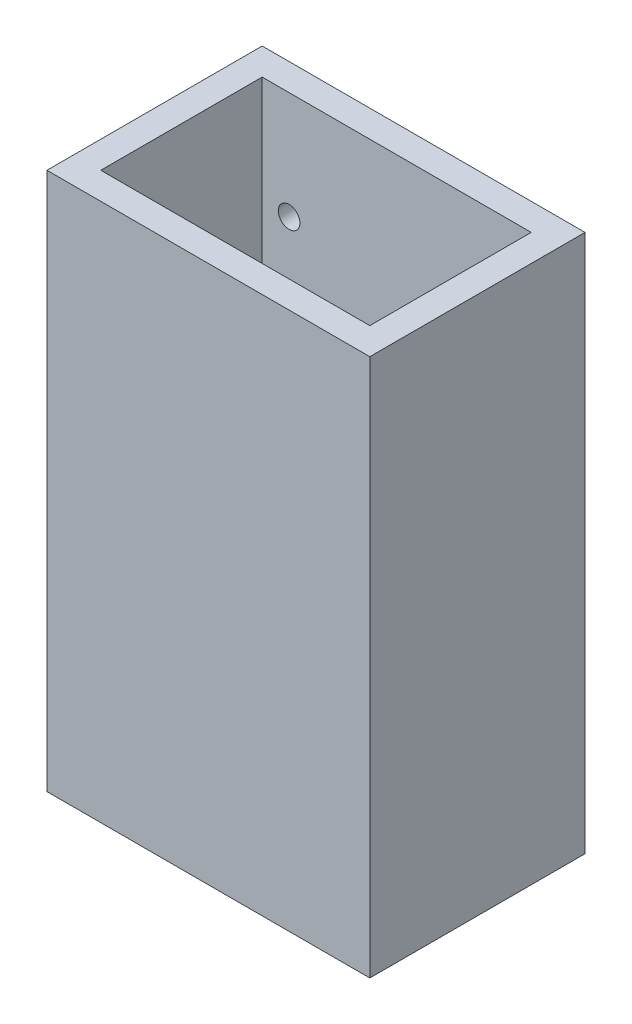
from build123d import *

# Parameters (mm, degrees)
SKETCH1_W                   = 76.2
SKETCH1_H                   = 50.8
SKETCH1_W_2                 = 63.5
SKETCH1_H_2                 = 38.1
BOSS_EXTRUDE1_DEPTH         = 127
F_1_4_20_TAPPED_HOLE1_D     = 5.1054
F_1_4_20_TAPPED_HOLE1_DEPTH = 6.35


with BuildPart() as part:
    # Sketch1 → Boss-Extrude1 (new body)
    with BuildSketch(Plane(origin=(0, 0, 0), x_dir=(1, 0, 0), z_dir=(0, 1, 0))):
        Rectangle(SKETCH1_W, SKETCH1_H)
        Rectangle(SKETCH1_W_2, SKETCH1_H_2, mode=Mode.SUBTRACT)
    extrude(amount=BOSS_EXTRUDE1_DEPTH)

    # 1/4-20 Tapped Hole1
    with Locations(Plane(origin=(0, 0, -25.4), x_dir=(-1, 0, 0), z_dir=(0, 0, -1))):
        with Locations((-25.4, 101.6), (-25.4, 25.4), (25.4, 25.4), (25.4, 101.6)):
            Hole(F_1_4_20_TAPPED_HOLE1_D / 2, depth=F_1_4_20_TAPPED_HOLE1_DEPTH)


solid = part.part
